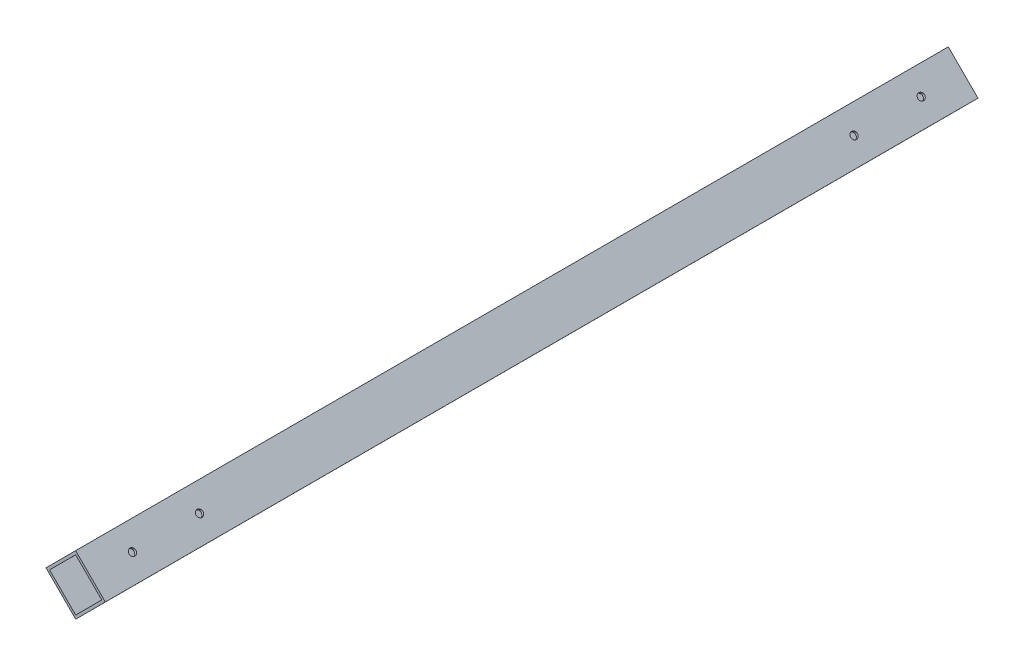
from build123d import *

# Parameters (mm, degrees)
EXTRUDE_1_DEPTH     = 520
SKETCH_2_R          = 2
CUT_EXTRUDE_1_DEPTH = 38.499979182


with BuildPart() as part:
    # 草圖1 → 填料-伸長1 (new body)
    with BuildSketch(Plane.XY):
        Polygon((0, 0), (17.69379362, -17.661530719), (0.032262901, -35.355324339), (-17.661530719, -17.69379362), align=None)
        Polygon((0.001935774, -2.12131946), (-15.540211259, -17.691857846), (0.030327127, -33.234004879), (15.57247416, -17.663466493), align=None, mode=Mode.SUBTRACT)
    extrude(amount=EXTRUDE_1_DEPTH)

    # 草圖2 → 除料-伸長1 (cut, through all)
    with BuildSketch(Plane(origin=(0, 0, 0), x_dir=(0.707751745, -0.706461229, 0), z_dir=(0.706461229, 0.707751745, 0))):
        with Locations((12.5, -455)):
            Circle(SKETCH_2_R)
        with Locations((12.5, -495)):
            Circle(SKETCH_2_R)
        with Locations((12.5, -25)):
            Circle(SKETCH_2_R)
        with Locations((12.5, -65)):
            Circle(SKETCH_2_R)
    extrude(amount=-CUT_EXTRUDE_1_DEPTH, mode=Mode.SUBTRACT)


solid = part.part
